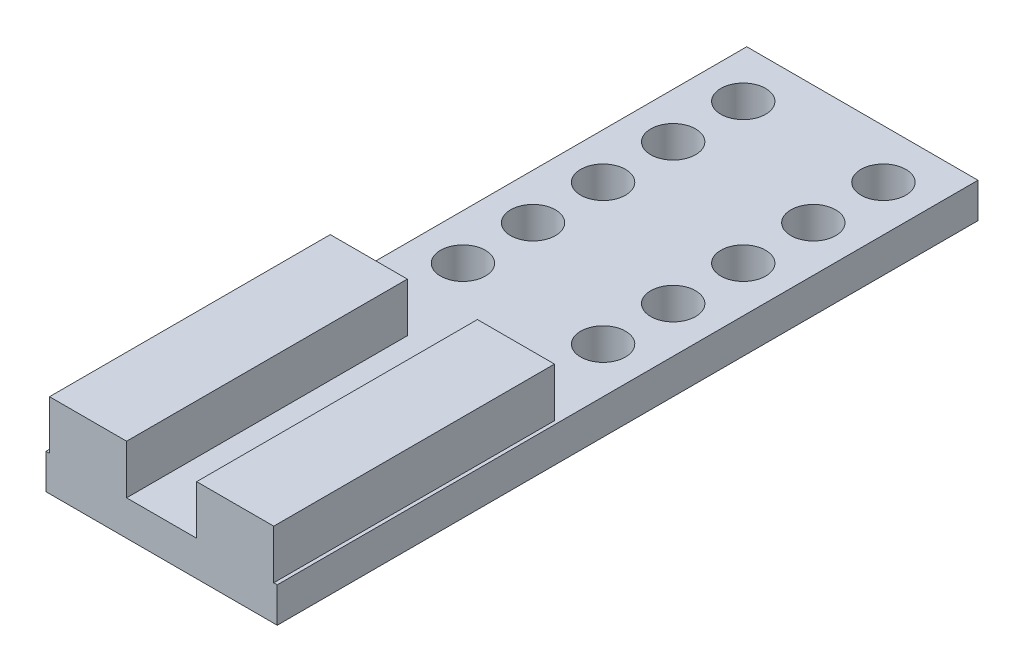
from build123d import *

# Parameters (mm, degrees)
SKETCH1_W           = 16.5
SKETCH1_H           = 50
BOSS_EXTRUDE1_DEPTH = 2.5
SKETCH2_W           = 5.5
SKETCH2_H           = 20.032642475
BOSS_EXTRUDE2_DEPTH = 3.5
SKETCH4_R           = 1.6
CUT_EXTRUDE1_DEPTH  = 3.5
LPATTERN1_COUNT     = 5
LPATTERN1_PITCH     = 5


with BuildPart() as part:
    # Sketch1 → Boss-Extrude1 (new body)
    with BuildSketch(Plane(origin=(0, 0, 0), x_dir=(1, 0, 0), z_dir=(0, 1, 0))):
        Rectangle(SKETCH1_W, SKETCH1_H)
    extrude(amount=-BOSS_EXTRUDE1_DEPTH)

    # Sketch2 → Boss-Extrude2 (add)
    with BuildSketch(Plane(origin=(0, 0, 0), x_dir=(1, 0, 0), z_dir=(0, 1, 0))):
        with Locations((-5.25, -14.983678763)):
            Rectangle(SKETCH2_W, SKETCH2_H)
        with Locations((5.25, -14.983678763)):
            Rectangle(SKETCH2_W, SKETCH2_H)
    extrude(amount=BOSS_EXTRUDE2_DEPTH)

    # Sketch4 → Cut-Extrude1 (cut, through all)
    with BuildSketch(Plane(origin=(0, 0, 0), x_dir=(1, 0, 0), z_dir=(0, 1, 0))):
        with Locations((-5, 21.5)):
            Circle(SKETCH4_R)
        with Locations((5, 21.5)):
            Circle(SKETCH4_R)
    cut_extrude1 = extrude(amount=-CUT_EXTRUDE1_DEPTH, mode=Mode.SUBTRACT)

    # LPattern1: Cut-Extrude1 ×5
    with Locations(*[(0, 0, i * LPATTERN1_PITCH) for i in range(1, LPATTERN1_COUNT)]):
        add(cut_extrude1, mode=Mode.SUBTRACT)


solid = part.part
